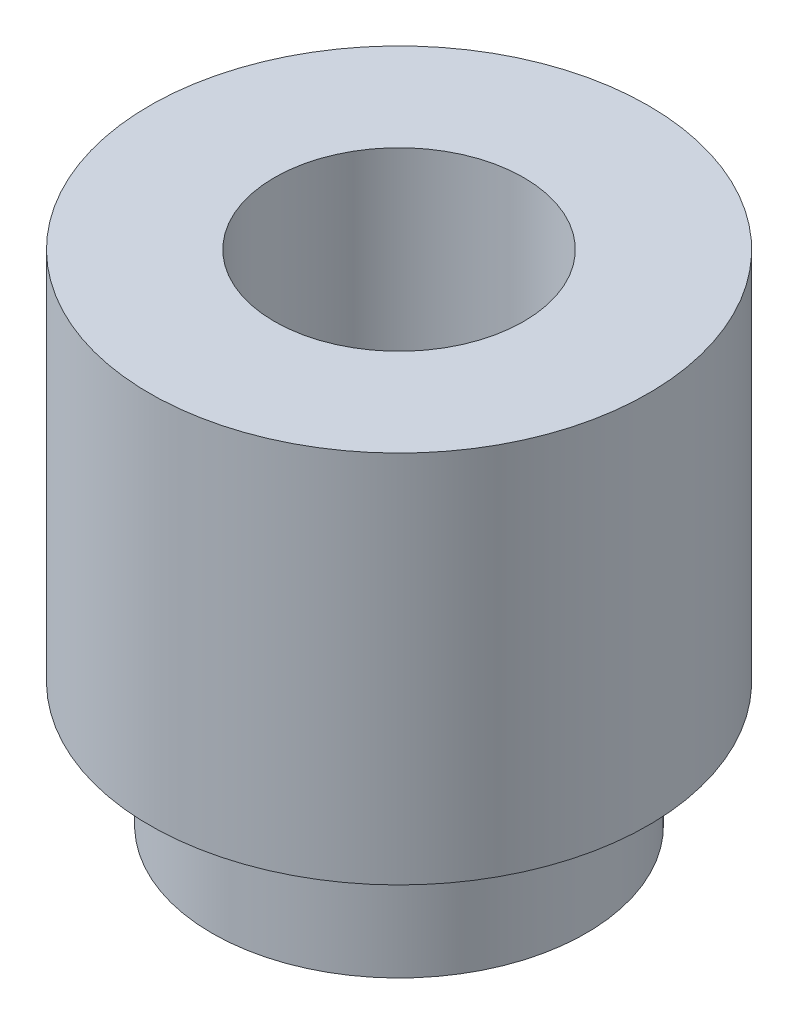
from build123d import *


with BuildPart() as part:
    # Sketch1 → Revolve1 (revolve)
    with BuildSketch(Plane(origin=(0, 0, 0), x_dir=(0, 0, -1), z_dir=(1, 0, 0))):
        Polygon((1, 4), (1, 0), (1.5, 0), (1.5, 1), (2, 1), (2, 4), align=None)
    revolve(axis=Axis((0, 0, 0), (0, 1, 0)))


solid = part.part
